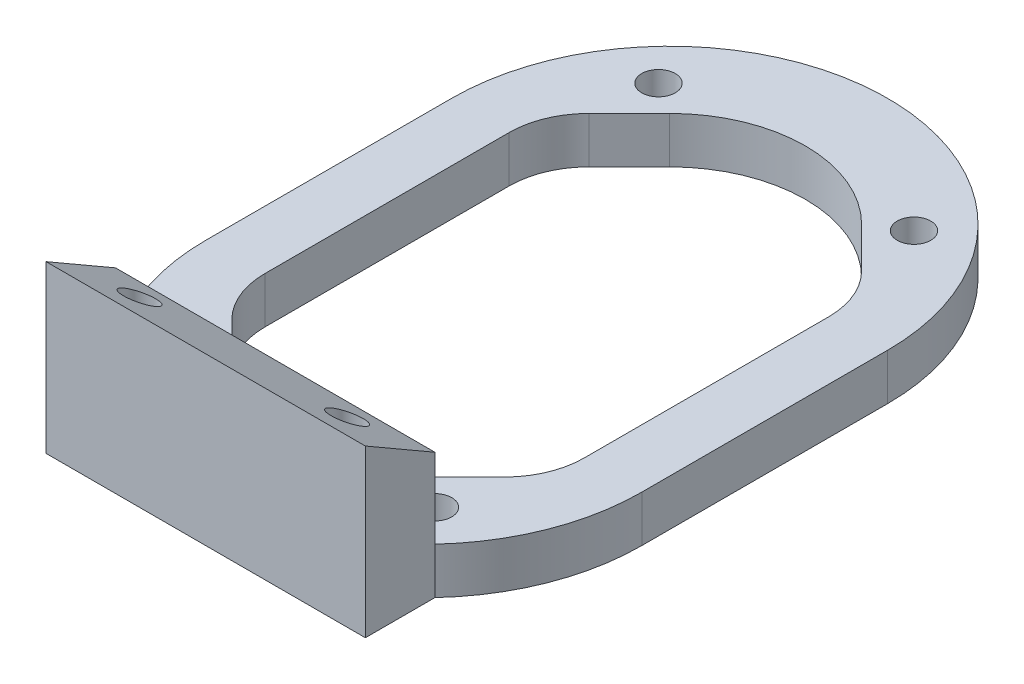
from build123d import *

# Parameters (mm, degrees)
BOSS_EXTRUDE6_DEPTH      = 2.9
SKETCH27_R               = 1.05
CUT_EXTRUDE12_DEPTH      = 3.9
SKETCH29_W               = 20
SKETCH29_H               = 4.356134153
BOSS_EXTRUDE8_DEPTH      = 11.5
BOSS_EXTRUDE8_DEPTH_BACK = 2.9
CUT_EXTRUDE16_DEPTH      = 24.656134153
SKETCH34_R               = 1
CUT_EXTRUDE17_DEPTH      = 11.4
CUT_EXTRUDE18_DEPTH      = 3.9
FILLET1_R                = 5
FILLET1_OF_MIRROR1_R     = 5


with BuildPart() as part:
    # Sketch26 → Boss-Extrude6 (new body)
    with BuildSketch(Plane(origin=(0, 0, 0), x_dir=(1, 0, 0), z_dir=(0, 1, 0))):
        with BuildLine():
            Line((-13.656134153, -7.7), (-13.656134153, 7.7))
            ThreePointArc((-13.656134153, 7.7), (0, 21.356134153), (13.656134153, 7.7))
            Line((13.656134153, 7.7), (13.656134153, -7.7))
            ThreePointArc((13.656134153, -7.7), (0, -21.356134153), (-13.656134153, -7.7))
        make_face()
        with BuildLine():
            Line((-8.5, 7.7), (-8.5, -7.7))
            ThreePointArc((-8.5, -7.7), (0, -16.2), (8.5, -7.7))
            Line((8.5, -7.7), (8.5, 7.7))
            ThreePointArc((8.5, 7.7), (0, 16.2), (-8.5, 7.7))
        make_face(mode=Mode.SUBTRACT)
    extrude(amount=BOSS_EXTRUDE6_DEPTH)

    # Sketch27 → Cut-Extrude12 (cut, through all)
    with BuildSketch(Plane(origin=(0, 2.9, 0), x_dir=(1, 0, 0), z_dir=(0, 1, 0))):
        with Locations((-8, 15)):
            Circle(SKETCH27_R)
        with Locations((8, 15)):
            Circle(SKETCH27_R)
        with Locations((8, -15)):
            Circle(SKETCH27_R)
        with Locations((-8, -15)):
            Circle(SKETCH27_R)
    extrude(amount=-CUT_EXTRUDE12_DEPTH, mode=Mode.SUBTRACT)

    # Sketch29 → Boss-Extrude8 (add, two sides)
    with BuildSketch(Plane(origin=(0, 2.9, 0), x_dir=(1, 0, 0), z_dir=(0, 1, 0))) as boss_extrude8_sk:
        with Locations((0, -19.178067076)):
            Rectangle(SKETCH29_W, SKETCH29_H)
    extrude(amount=BOSS_EXTRUDE8_DEPTH)
    extrude(boss_extrude8_sk.sketch, amount=-BOSS_EXTRUDE8_DEPTH_BACK)

    # Sketch33 → Cut-Extrude16 (cut, through all)
    with BuildSketch(Plane(origin=(10, 0, 0), x_dir=(0, 0, -1), z_dir=(1, 0, 0))):
        Polygon((-21.356134153, 14.4), (-21.356134153, 10.4), (-17, 7.884984774), (-17, 14.4), align=None)
    extrude(amount=-CUT_EXTRUDE16_DEPTH, mode=Mode.SUBTRACT)

    # Sketch34 → Cut-Extrude17 (cut, through all)
    with BuildSketch(Plane.XZ):
        with Locations((6.5, 19)):
            Circle(SKETCH34_R)
        with Locations((-6.5, 19)):
            Circle(SKETCH34_R)
    extrude(amount=-CUT_EXTRUDE17_DEPTH, mode=Mode.SUBTRACT)

    # Sketch35 → Cut-Extrude18 (cut, through all)
    with BuildSketch(Plane(origin=(0, 2.9, 0), x_dir=(1, 0, 0), z_dir=(0, 1, 0))):
        Polygon((-10, 9.72081528), (-10, -9.72081528), (-6.01040764, -13.71040764), (-6.01040764, 13.71040764), align=None)
    cut_extrude18 = extrude(amount=-CUT_EXTRUDE18_DEPTH, mode=Mode.SUBTRACT)

    # Fillet1
    fillet1_edges = [part.edges().sort_by_distance(p)[0] for p in [
        (-10, 1.45, -9.72081528),
        (-10, 1.45, 9.72081528),
    ]]
    fillet(fillet1_edges, radius=FILLET1_R)

    # Mirror1: Cut-Extrude18 across plane
    add(cut_extrude18.mirror(Plane(origin=(0, 0, 0), x_dir=(0, 0, 1), z_dir=(1, 0, 0))), mode=Mode.SUBTRACT)

    # Fillet1 of Mirror1
    fillet1_of_mirror1_edges = [part.edges().sort_by_distance(p)[0] for p in [
        (10, 1.45, -9.72081528),
        (10, 1.45, 9.72081528),
    ]]
    fillet(fillet1_of_mirror1_edges, radius=FILLET1_OF_MIRROR1_R)


solid = part.part
